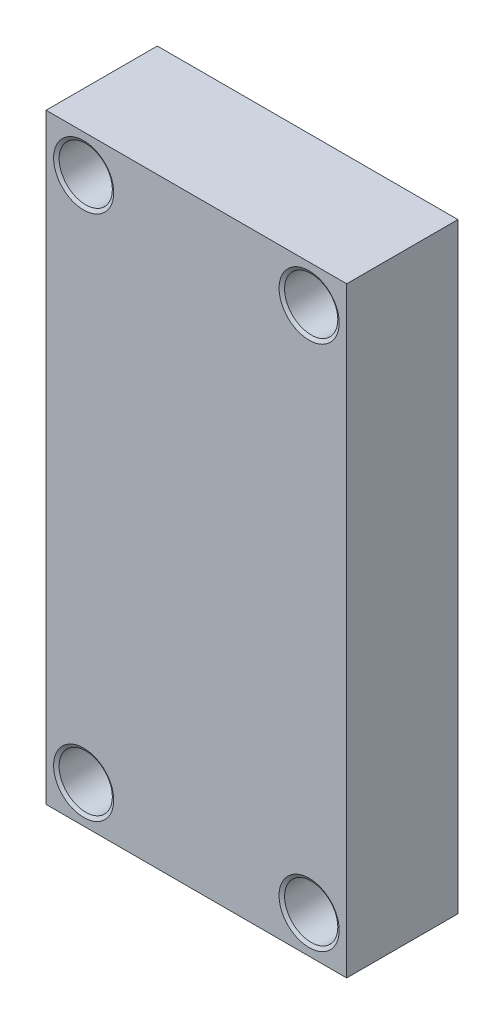
from build123d import *

# Parameters (mm, degrees)
SKETCH1_W            = 25.4
SKETCH1_H            = 50.8
BOSS_EXTRUDE1_DEPTH  = 9.398
LPATTERN1_COUNT      = 2
LPATTERN1_PITCH      = 44.45
LPATTERN1_COUNT_DIR2 = 2
LPATTERN1_PITCH_DIR2 = 19.05


with BuildPart() as part:
    # Sketch1 → Boss-Extrude1 (new body)
    with BuildSketch(Plane.XY):
        Rectangle(SKETCH1_W, SKETCH1_H)
    extrude(amount=BOSS_EXTRUDE1_DEPTH)

    # Sketch3 → #8 Clearance Hole1 (revolve, cut)
    with BuildSketch(Plane(origin=(-9.525, -22.225, 9.398), x_dir=(0, -1, 0), z_dir=(1, 0, 0))):
        Polygon((0, 0), (0, 9.398), (2.54, 9.398), (2.2479, 9.222488613), (2.2479, 0.175511387), (2.54, 0), align=None)
    f_8_clearance_hole1 = revolve(axis=Axis((-9.525, -22.225, 15.748), (0, 0, -1)), mode=Mode.SUBTRACT)

    # LPattern1: 8 Clearance Hole1 2 × 2
    with Locations(*[(j * LPATTERN1_PITCH_DIR2, i * LPATTERN1_PITCH, 0) for i in range(LPATTERN1_COUNT) for j in range(LPATTERN1_COUNT_DIR2) if (i, j) != (0, 0)]):
        add(f_8_clearance_hole1, mode=Mode.SUBTRACT)


solid = part.part
